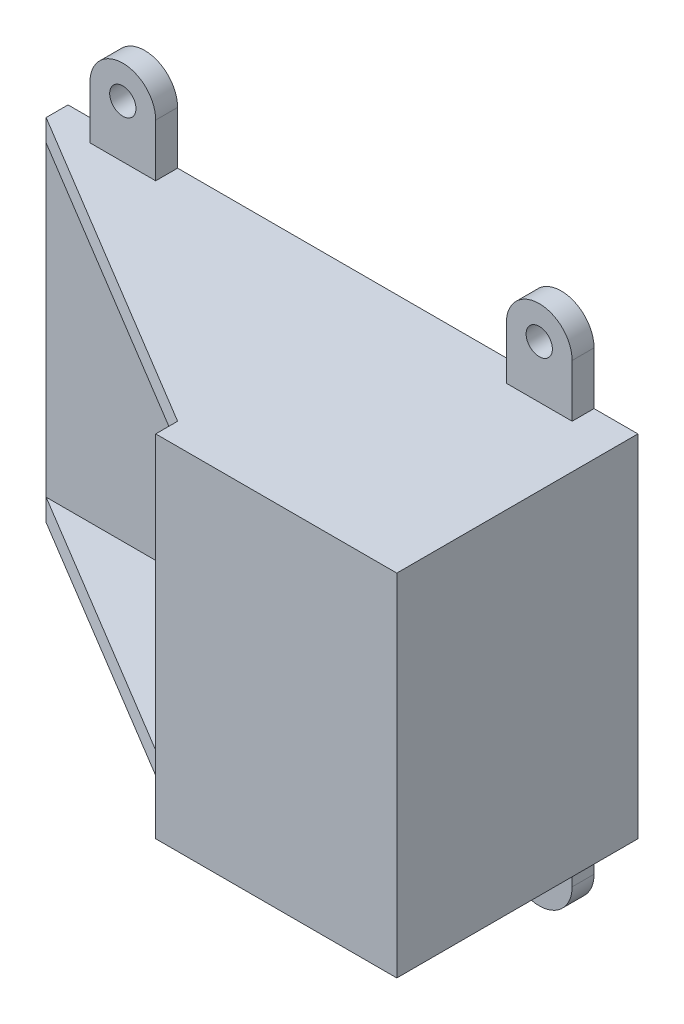
from build123d import *

# Parameters (mm, degrees)
SKETCH_1_W             = 125
SKETCH_1_H             = 70
EXTRUDE_1_DEPTH        = 5
EXTRUDE_2_DEPTH        = 5
PATTERN_LINEAR_1_COUNT = 2
PATTERN_LINEAR_1_PITCH = 75
SKETCH_4_W             = 50
SKETCH_4_H             = 80
EXTRUDE_3_DEPTH        = 5
SKETCH_5_W             = 55
SKETCH_5_H             = 80
EXTRUDE_4_DEPTH        = 5
EXTRUDE_5_DEPTH        = 5
PATTERN_LINEAR_2_COUNT = 2
PATTERN_LINEAR_2_PITCH = 95
MIRROR_1_COPY_1_DEPTH  = 5


with BuildPart() as part:
    # 草圖1 → 填料-伸長1 (new body)
    with BuildSketch(Plane.XY):
        with Locations((62.5, 35)):
            Rectangle(SKETCH_1_W, SKETCH_1_H)
    extrude(amount=EXTRUDE_1_DEPTH)

    # 草圖2 → 填料-伸長2 (add)
    with BuildSketch(Plane.XZ):
        Polygon((75, 50), (0, 5), (0, 0), (125, 0), (125, 50), align=None)
    extrude_2 = extrude(amount=EXTRUDE_2_DEPTH)

    # 直線複製排列1: 填料-伸長2 ×2
    with Locations(*[(0, i * PATTERN_LINEAR_1_PITCH, 0) for i in range(1, PATTERN_LINEAR_1_COUNT)]):
        add(extrude_2)

    # 草圖4 → 填料-伸長3 (add)
    with BuildSketch(Plane(origin=(125, 0, 0), x_dir=(0, 0, -1), z_dir=(1, 0, 0))):
        with Locations((-25, 35)):
            Rectangle(SKETCH_4_W, SKETCH_4_H)
    extrude(amount=EXTRUDE_3_DEPTH)

    # 草圖5 → 填料-伸長4 (add)
    with BuildSketch(Plane.XY.offset(50)):
        with Locations((102.5, 35)):
            Rectangle(SKETCH_5_W, SKETCH_5_H)
    extrude(amount=EXTRUDE_4_DEPTH)

    # 草圖6 → 填料-伸長5 (add)
    with BuildSketch(Plane.XY):
        with BuildLine():
            Line((25, -5), (10, -5))
            Line((10, -5), (10, -17))
            ThreePointArc((10, -17), (17.5, -9.5), (25, -17))
            Line((25, -17), (25, -5))
        make_face()
        with BuildLine():
            ThreePointArc((25, -17), (17.5, -9.5), (10, -17))
            Line((10, -17), (14.5, -17))
            ThreePointArc((14.5, -17), (17.5, -14), (20.5, -17))
            Line((20.5, -17), (25, -17))
        make_face()
        with BuildLine():
            Line((14.5, -17), (10, -17))
            ThreePointArc((10, -17), (17.5, -24.5), (25, -17))
            Line((25, -17), (20.5, -17))
            ThreePointArc((20.5, -17), (17.5, -20), (14.5, -17))
        make_face()
    extrude_5 = extrude(amount=EXTRUDE_5_DEPTH)

    # 直線複製排列2: 填料-伸長5 ×2
    with Locations(*[(i * PATTERN_LINEAR_2_PITCH, 0, 0) for i in range(1, PATTERN_LINEAR_2_COUNT)]):
        add(extrude_5)

    # 鏡射1: 填料-伸長5 across plane
    add(extrude_5.mirror(Plane.ZX.offset(35)))

    # 鏡射1 copy 1 sketch → 鏡射1 copy 1 (add)
    with BuildSketch(Plane(origin=(95, 70, 0), x_dir=(1, 0, 0), z_dir=(0, 0, 1))):
        with BuildLine():
            Line((25, 5), (10, 5))
            Line((10, 5), (10, 17))
            ThreePointArc((10, 17), (17.5, 9.5), (25, 17))
            Line((25, 17), (25, 5))
        make_face()
        with BuildLine():
            ThreePointArc((25, 17), (17.5, 9.5), (10, 17))
            Line((10, 17), (14.5, 17))
            ThreePointArc((14.5, 17), (17.5, 14), (20.5, 17))
            Line((20.5, 17), (25, 17))
        make_face()
        with BuildLine():
            Line((14.5, 17), (10, 17))
            ThreePointArc((10, 17), (17.5, 24.5), (25, 17))
            Line((25, 17), (20.5, 17))
            ThreePointArc((20.5, 17), (17.5, 20), (14.5, 17))
        make_face()
    extrude(amount=MIRROR_1_COPY_1_DEPTH)


solid = part.part
